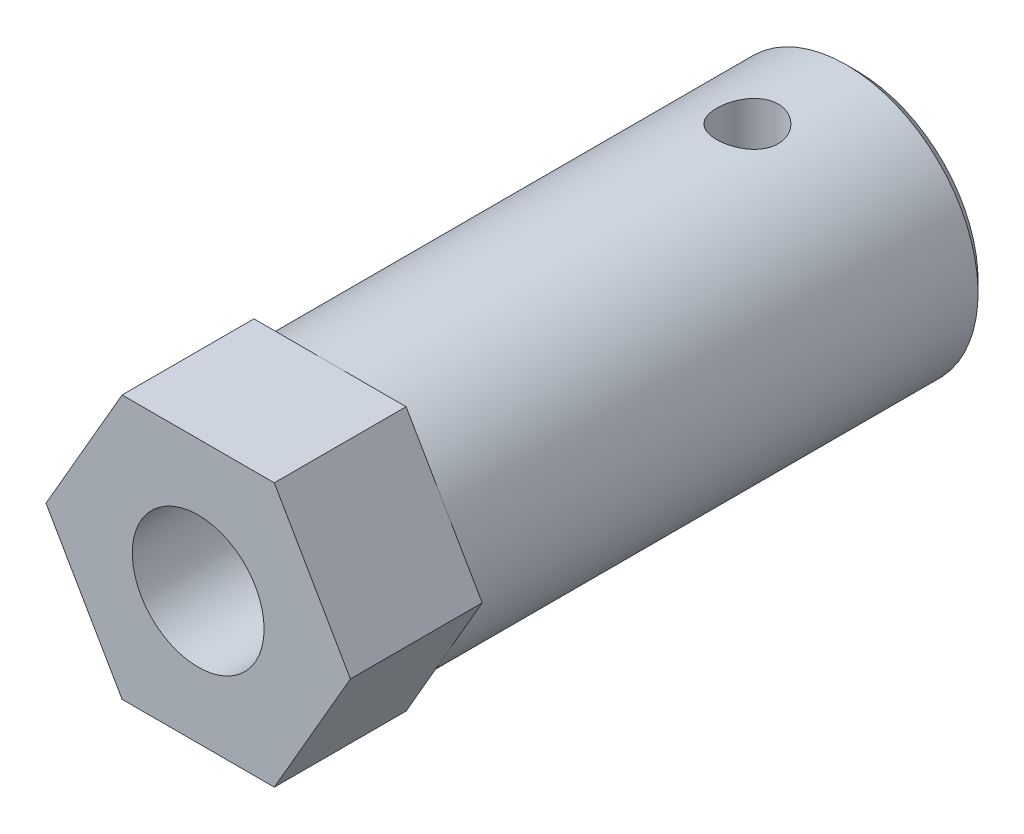
from build123d import *

# Parameters (mm, degrees)
ESQUISSE1_W                  = 24
ESQUISSE1_H                  = 6
BOSS_EXTRU_1_DEPTH           = 6
ENL_V_MAT_EXTRU_1_REACH      = 32
ESQUISSE3_R                  = 3
ESQUISSE4_R                  = 1.400948466
ENL_V_MAT_EXTRU_2_DEPTH      = 7
ENL_V_MAT_EXTRU_2_DEPTH_BACK = 7
CHANFREIN1_SIZE              = 0.5


with BuildPart() as part:
    # Esquisse1 → Révolution1 (revolve)
    with BuildSketch(Plane(origin=(0, 0, 0), x_dir=(0, 0, -1), z_dir=(1, 0, 0))):
        with Locations((-12, 3)):
            Rectangle(ESQUISSE1_W, ESQUISSE1_H)
    revolve(axis=Axis((0, 0, 0), (0, 0, 1)))

    # Esquisse2 → Boss.-Extru.1 (add)
    with BuildSketch(Plane.XY.offset(24)):
        Polygon((6.92820323, 0), (3.464101615, 6), (-3.464101615, 6), (-6.92820323, 0), (-3.464101615, -6), (3.464101615, -6), align=None)
    extrude(amount=BOSS_EXTRU_1_DEPTH)

    # Esquisse3 → Enlèv. mat.-Extru.1 (cut, up to next)
    with BuildSketch(Plane(origin=(0, 0, 0), x_dir=(-1, 0, 0), z_dir=(0, 0, -1)), mode=Mode.PRIVATE) as enl_v_mat_extru_1_sk1:
        Circle(ESQUISSE3_R)
    enl_v_mat_extru_1_tool1 = extrude(enl_v_mat_extru_1_sk1.sketch, amount=-ENL_V_MAT_EXTRU_1_REACH, mode=Mode.PRIVATE) & part.part
    add(enl_v_mat_extru_1_tool1.solids().sort_by_distance((0, 0, 0))[0], mode=Mode.SUBTRACT)

    # Esquisse4 → Enlèv. mat.-Extru.2 (cut, two sides)
    with BuildSketch(Plane(origin=(0, 0, 0), x_dir=(1, 0, 0), z_dir=(0, 1, 0))) as enl_v_mat_extru_2_sk:
        with Locations((0, -5)):
            Circle(ESQUISSE4_R)
    extrude(amount=ENL_V_MAT_EXTRU_2_DEPTH, mode=Mode.SUBTRACT)
    extrude(enl_v_mat_extru_2_sk.sketch, amount=-ENL_V_MAT_EXTRU_2_DEPTH_BACK, mode=Mode.SUBTRACT)

    # Chanfrein1
    chanfrein1_edges = [part.edges().sort_by_distance(p)[0] for p in [
        (0, -6, 0),
    ]]
    chamfer(chanfrein1_edges, length=CHANFREIN1_SIZE)


solid = part.part
